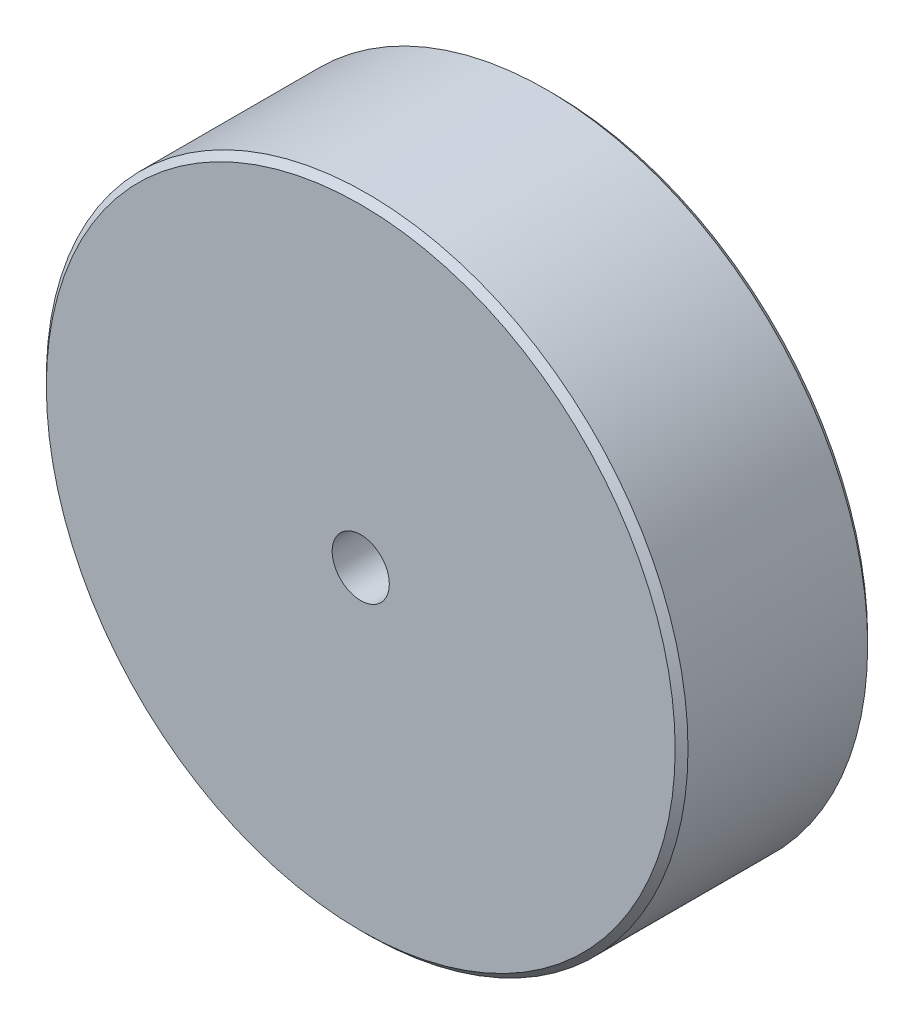
from build123d import *

# Parameters (mm, degrees)
SKETCH1_R                 = 12.7
BOSS_EXTRUDE1_DEPTH       = 7.62
F_4_40_TAPPED_HOLE1_D     = 2.2606
F_4_40_TAPPED_HOLE1_DEPTH = 5.670847242
F_4_40_TAPPED_HOLE1_TIP   = 0.679152758
CHAMFER1_SIZE             = 0.254


with BuildPart() as part:
    # Sketch1 → Boss-Extrude1 (new body)
    with BuildSketch(Plane.XY):
        Circle(SKETCH1_R)
    extrude(amount=BOSS_EXTRUDE1_DEPTH)

    # #4-40 Tapped Hole1
    with Locations(Plane.XY.offset(7.62)):
        with Locations((0, 0)):
            Hole(F_4_40_TAPPED_HOLE1_D / 2, depth=F_4_40_TAPPED_HOLE1_DEPTH)
            with Locations((0, 0, -(F_4_40_TAPPED_HOLE1_DEPTH + F_4_40_TAPPED_HOLE1_TIP / 2))):  # 118° drill point
                Cone(0, F_4_40_TAPPED_HOLE1_D / 2, F_4_40_TAPPED_HOLE1_TIP, mode=Mode.SUBTRACT)

    # Chamfer1
    chamfer1_edges = [part.edges().sort_by_distance(p)[0] for p in [
        (-12.7, 0, 0),
        (-12.7, 0, 7.62),
    ]]
    chamfer(chamfer1_edges, length=CHAMFER1_SIZE)


solid = part.part
